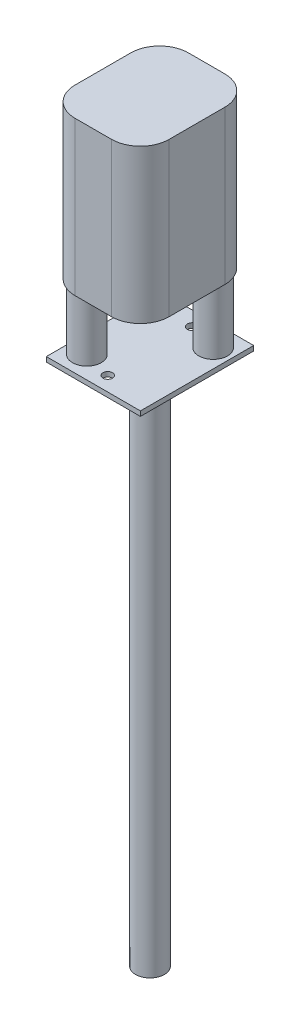
from build123d import *

# Parameters (mm, degrees)
SKETCH1_W           = 9.8
SKETCH1_H           = 11.8
BOSS_EXTRUDE1_DEPTH = 0.5
SKETCH2_R           = 1.5
BOSS_EXTRUDE2_DEPTH = 55
SKETCH5_R           = 0.5
CUT_EXTRUDE1_DEPTH  = 55
SKETCH6_R           = 1.5
BOSS_EXTRUDE3_DEPTH = 7
BOSS_EXTRUDE4_DEPTH = 16


with BuildPart() as part:
    # Sketch1 → Boss-Extrude1 (new body)
    with BuildSketch(Plane(origin=(0, 0, 0), x_dir=(1, 0, 0), z_dir=(0, 1, 0))):
        Rectangle(SKETCH1_W, SKETCH1_H)
    extrude(amount=BOSS_EXTRUDE1_DEPTH)

    # Sketch2 → Boss-Extrude2 (add)
    with BuildSketch(Plane.XZ):
        Circle(SKETCH2_R)
    extrude(amount=BOSS_EXTRUDE2_DEPTH)

    # Sketch5 → Cut-Extrude1 (cut)
    with BuildSketch(Plane.XZ):
        with Locations((0, 4.4)):
            Circle(SKETCH5_R)
        with Locations((0, -4.4)):
            Circle(SKETCH5_R)
    extrude(amount=-CUT_EXTRUDE1_DEPTH, mode=Mode.SUBTRACT)

    # Sketch6 → Boss-Extrude3 (add)
    with BuildSketch(Plane(origin=(0, 0.5, 0), x_dir=(1, 0, 0), z_dir=(0, 1, 0))):
        with Locations((-2.983296991, -3.592133112)):
            Circle(SKETCH6_R)
        with Locations((2.983296991, 3.592133112)):
            Circle(SKETCH6_R)
    extrude(amount=BOSS_EXTRUDE3_DEPTH)

    # Sketch7 → Boss-Extrude4 (add)
    with BuildSketch(Plane(origin=(0, 7.5, 0), x_dir=(1, 0, 0), z_dir=(0, 1, 0))):
        with BuildLine():
            Line((-1.9, 5.9), (1.9, 5.9))
            ThreePointArc((1.9, 5.9), (4.021320344, 5.021320344), (4.9, 2.9))
            Line((4.9, 2.9), (4.9, -2.907128276))
            ThreePointArc((4.9, -2.907128276), (4.021320344, -5.028448619), (1.9, -5.907128276))
            Line((1.9, -5.907128276), (-1.9, -5.907128276))
            ThreePointArc((-1.9, -5.907128276), (-4.021320344, -5.028448619), (-4.9, -2.907128276))
            Line((-4.9, -2.907128276), (-4.9, 2.9))
            ThreePointArc((-4.9, 2.9), (-4.021320344, 5.021320344), (-1.9, 5.9))
        make_face()
    extrude(amount=BOSS_EXTRUDE4_DEPTH)


solid = part.part
